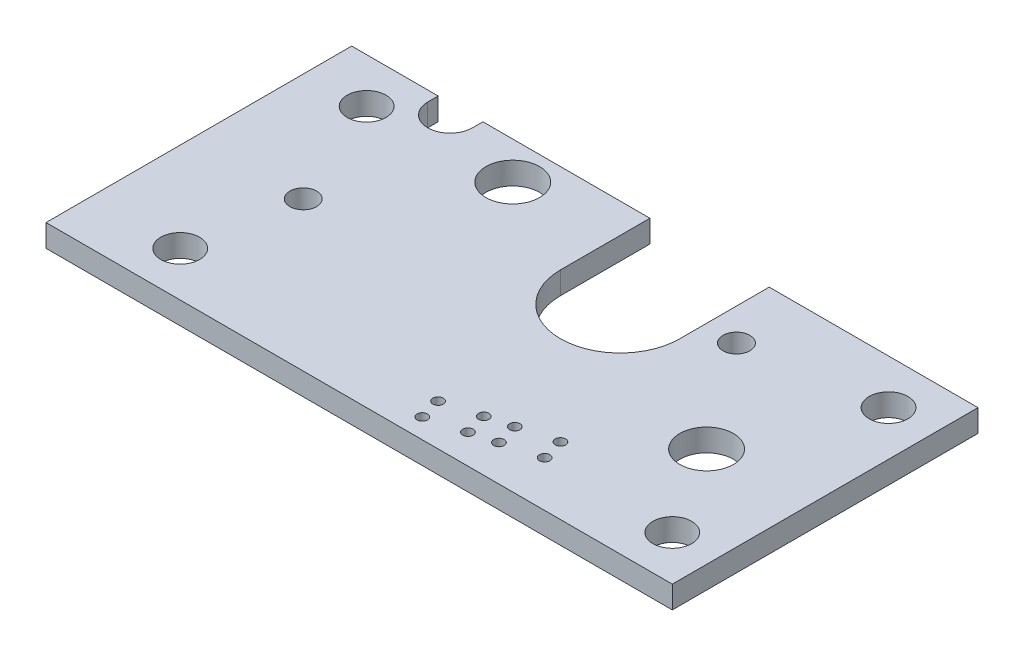
from build123d import *

# Parameters (mm, degrees)
SKETCH_1_W          = 42
SKETCH_1_H          = 20.5
EXTRUDE_1_DEPTH     = 1.5
SKETCH_2_R          = 4
CUT_EXTRUDE_1_DEPTH = 2.5
CUT_EXTRUDE_3_REACH = 3.5
SKETCH_4_R          = 0.9
SKETCH_4_R_2        = 1.3
SKETCH_4_R_3        = 1.8
SKETCH_5_R          = 0.35
CUT_EXTRUDE_4_DEPTH = 2.5


with BuildPart() as part:
    # Эскиз1 → Бобышка-Вытянуть1 (new body)
    with BuildSketch(Plane(origin=(0, 0, 0), x_dir=(1, 0, 0), z_dir=(0, 1, 0))):
        with Locations((21, 10.25)):
            Rectangle(SKETCH_1_W, SKETCH_1_H)
    extrude(amount=EXTRUDE_1_DEPTH)

    # Эскиз2 → Вырез-Вытянуть1 (cut, through all)
    with BuildSketch(Plane(origin=(0, 1.5, 0), x_dir=(1, 0, 0), z_dir=(0, 1, 0))):
        with Locations((24, 14.5)):
            Circle(SKETCH_2_R)
        with BuildLine():
            Line((20, 20.5), (20, 14.5))
            ThreePointArc((20, 14.5), (24, 18.5), (28, 14.5))
            Line((28, 14.5), (28, 20.5))
            Line((28, 20.5), (20, 20.5))
        make_face()
    extrude(amount=-CUT_EXTRUDE_1_DEPTH, mode=Mode.SUBTRACT)

    # Эскиз4 → Вырез-Вытянуть3 (cut, up to next)
    with BuildSketch(Plane(origin=(0, 1.5, 0), x_dir=(1, 0, 0), z_dir=(0, 1, 0)), mode=Mode.PRIVATE) as cut_extrude_3_sk1:
        with BuildLine():
            Line((5.8, 20.5), (5.8, 19.8))
            ThreePointArc((5.8, 19.8), (7.3, 18.3), (8.8, 19.8))
            Line((8.8, 19.8), (8.8, 20.5))
            Line((8.8, 20.5), (5.8, 20.5))
        make_face()
    cut_extrude_3_tool1 = extrude(cut_extrude_3_sk1.sketch, amount=-CUT_EXTRUDE_3_REACH, mode=Mode.PRIVATE) & part.part
    add(cut_extrude_3_tool1.solids().sort_by_distance((7.3, 1.5, -19.531111))[0], mode=Mode.SUBTRACT)
    # Эскиз4 → Вырез-Вытянуть3 (cut, up to next)
    with BuildSketch(Plane(origin=(0, 1.5, 0), x_dir=(1, 0, 0), z_dir=(0, 1, 0)), mode=Mode.PRIVATE) as cut_extrude_3_sk2:
        with Locations((7.25, 10)):
            Circle(SKETCH_4_R)
    cut_extrude_3_tool2 = extrude(cut_extrude_3_sk2.sketch, amount=-CUT_EXTRUDE_3_REACH, mode=Mode.PRIVATE) & part.part
    add(cut_extrude_3_tool2.solids().sort_by_distance((7.25, 1.5, -10))[0], mode=Mode.SUBTRACT)
    # Эскиз4 → Вырез-Вытянуть3 (cut, up to next)
    with BuildSketch(Plane(origin=(0, 1.5, 0), x_dir=(1, 0, 0), z_dir=(0, 1, 0)), mode=Mode.PRIVATE) as cut_extrude_3_sk3:
        with Locations((30.15, 16.15)):
            Circle(SKETCH_4_R)
    cut_extrude_3_tool3 = extrude(cut_extrude_3_sk3.sketch, amount=-CUT_EXTRUDE_3_REACH, mode=Mode.PRIVATE) & part.part
    add(cut_extrude_3_tool3.solids().sort_by_distance((30.15, 1.5, -16.15))[0], mode=Mode.SUBTRACT)
    # Эскиз4 → Вырез-Вытянуть3 (cut, up to next)
    with BuildSketch(Plane(origin=(0, 1.5, 0), x_dir=(1, 0, 0), z_dir=(0, 1, 0)), mode=Mode.PRIVATE) as cut_extrude_3_sk4:
        with Locations((39, 3)):
            Circle(SKETCH_4_R_2)
    cut_extrude_3_tool4 = extrude(cut_extrude_3_sk4.sketch, amount=-CUT_EXTRUDE_3_REACH, mode=Mode.PRIVATE) & part.part
    add(cut_extrude_3_tool4.solids().sort_by_distance((39, 1.5, -3))[0], mode=Mode.SUBTRACT)
    # Эскиз4 → Вырез-Вытянуть3 (cut, up to next)
    with BuildSketch(Plane(origin=(0, 1.5, 0), x_dir=(1, 0, 0), z_dir=(0, 1, 0)), mode=Mode.PRIVATE) as cut_extrude_3_sk5:
        with Locations((39, 17.5)):
            Circle(SKETCH_4_R_2)
    cut_extrude_3_tool5 = extrude(cut_extrude_3_sk5.sketch, amount=-CUT_EXTRUDE_3_REACH, mode=Mode.PRIVATE) & part.part
    add(cut_extrude_3_tool5.solids().sort_by_distance((39, 1.5, -17.5))[0], mode=Mode.SUBTRACT)
    # Эскиз4 → Вырез-Вытянуть3 (cut, up to next)
    with BuildSketch(Plane(origin=(0, 1.5, 0), x_dir=(1, 0, 0), z_dir=(0, 1, 0)), mode=Mode.PRIVATE) as cut_extrude_3_sk6:
        with Locations((6, 3)):
            Circle(SKETCH_4_R_2)
    cut_extrude_3_tool6 = extrude(cut_extrude_3_sk6.sketch, amount=-CUT_EXTRUDE_3_REACH, mode=Mode.PRIVATE) & part.part
    add(cut_extrude_3_tool6.solids().sort_by_distance((6, 1.5, -3))[0], mode=Mode.SUBTRACT)
    # Эскиз4 → Вырез-Вытянуть3 (cut, up to next)
    with BuildSketch(Plane(origin=(0, 1.5, 0), x_dir=(1, 0, 0), z_dir=(0, 1, 0)), mode=Mode.PRIVATE) as cut_extrude_3_sk7:
        with Locations((4, 17.5)):
            Circle(SKETCH_4_R_2)
    cut_extrude_3_tool7 = extrude(cut_extrude_3_sk7.sketch, amount=-CUT_EXTRUDE_3_REACH, mode=Mode.PRIVATE) & part.part
    add(cut_extrude_3_tool7.solids().sort_by_distance((4, 1.5, -17.5))[0], mode=Mode.SUBTRACT)
    # Эскиз4 → Вырез-Вытянуть3 (cut, up to next)
    with BuildSketch(Plane(origin=(0, 1.5, 0), x_dir=(1, 0, 0), z_dir=(0, 1, 0)), mode=Mode.PRIVATE) as cut_extrude_3_sk8:
        with Locations((13.3, 18)):
            Circle(SKETCH_4_R_3)
    cut_extrude_3_tool8 = extrude(cut_extrude_3_sk8.sketch, amount=-CUT_EXTRUDE_3_REACH, mode=Mode.PRIVATE) & part.part
    add(cut_extrude_3_tool8.solids().sort_by_distance((13.3, 1.5, -18))[0], mode=Mode.SUBTRACT)
    # Эскиз4 → Вырез-Вытянуть3 (cut, up to next)
    with BuildSketch(Plane(origin=(0, 1.5, 0), x_dir=(1, 0, 0), z_dir=(0, 1, 0)), mode=Mode.PRIVATE) as cut_extrude_3_sk9:
        with Locations((35.3, 9)):
            Circle(SKETCH_4_R_3)
    cut_extrude_3_tool9 = extrude(cut_extrude_3_sk9.sketch, amount=-CUT_EXTRUDE_3_REACH, mode=Mode.PRIVATE) & part.part
    add(cut_extrude_3_tool9.solids().sort_by_distance((35.3, 1.5, -9))[0], mode=Mode.SUBTRACT)

    # Эскиз5 → Вырез-Вытянуть4 (cut, through all)
    with BuildSketch(Plane(origin=(0, 1.5, 0), x_dir=(1, 0, 0), z_dir=(0, 1, 0))):
        with Locations((29.989735949, 4.50985169)):
            Circle(SKETCH_5_R)
        with Locations((27.574921384, 3.862804077)):
            Circle(SKETCH_5_R)
        with Locations((25.932847479, 3.4228117)):
            Circle(SKETCH_5_R)
        with Locations((23.518032913, 2.775764088)):
            Circle(SKETCH_5_R)
        with Locations((30.377964517, 3.06096295)):
            Circle(SKETCH_5_R)
        with Locations((27.963149951, 2.413915338)):
            Circle(SKETCH_5_R)
        with Locations((26.321076047, 1.973922961)):
            Circle(SKETCH_5_R)
        with Locations((23.906261481, 1.326875348)):
            Circle(SKETCH_5_R)
    extrude(amount=-CUT_EXTRUDE_4_DEPTH, mode=Mode.SUBTRACT)


solid = part.part
